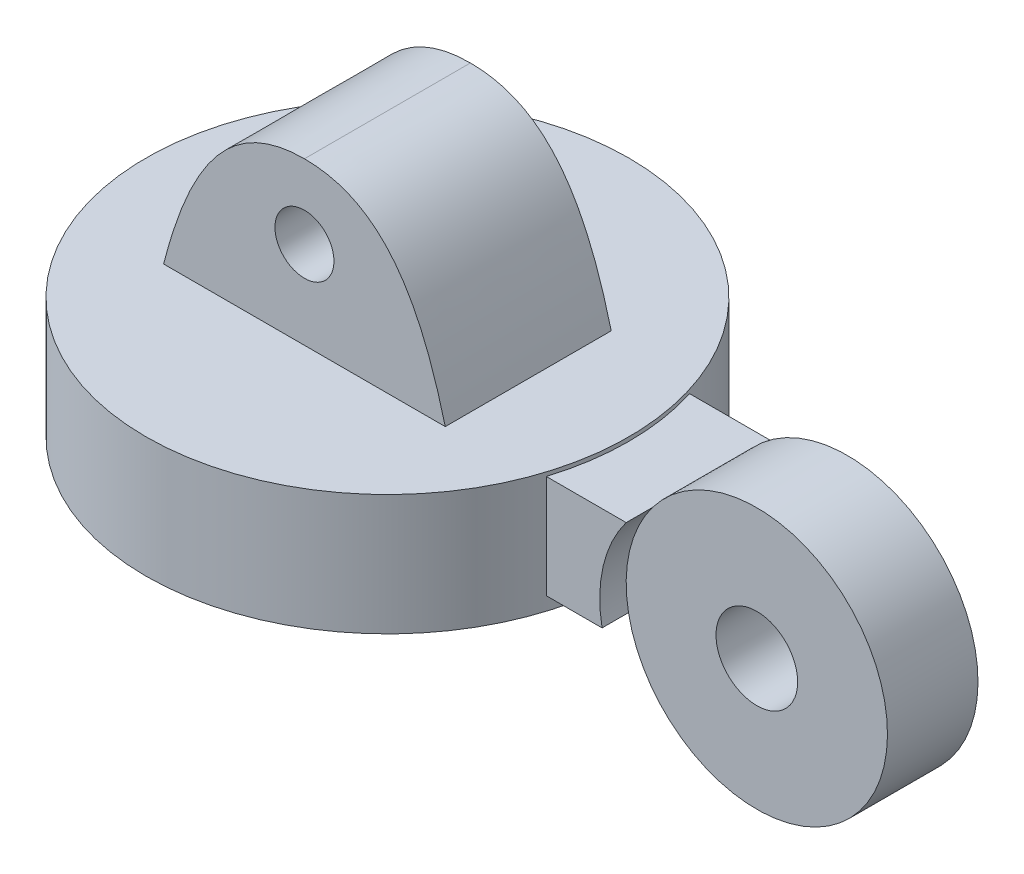
from build123d import *

# Parameters (mm, degrees)
SKETCH1_R           = 32.007465035
BOSS_EXTRUDE1_DEPTH = 16
SKETCH2_R           = 29.239508
SKETCH2_R_2         = 27.5
CUT_EXTRUDE1_DEPTH  = 3
SKETCH4_R           = 3.909700179
BOSS_EXTRUDE2_DEPTH = 11
BOSS_EXTRUDE3_DEPTH = 9.5
SKETCH5_3_R         = 5.411731441
BOSS_EXTRUDE4_DEPTH = 6


with BuildPart() as part:
    # Sketch1 → Boss-Extrude1 (new body)
    with BuildSketch(Plane(origin=(0, 0, 0), x_dir=(1, 0, 0), z_dir=(0, 1, 0))):
        Circle(SKETCH1_R)
    extrude(amount=BOSS_EXTRUDE1_DEPTH)

    # Sketch2 → Cut-Extrude1 (cut)
    with BuildSketch(Plane.XZ):
        Circle(SKETCH2_R)
        with Locations((-0.468052939, 0)):
            Circle(SKETCH2_R_2, mode=Mode.SUBTRACT)
    extrude(amount=-CUT_EXTRUDE1_DEPTH, mode=Mode.SUBTRACT)

    # Sketch4 → Boss-Extrude2 (add, symmetric)
    with BuildSketch(Plane.XY):
        with BuildLine():
            Line((18.666452957, 16), (-18.666452957, 16))
            add(Edge.make_bspline(
                [(-18.666452957, 16), (-15.111428576, 29.88911488), (-9.66036104, 37.412417949), (0, 37.412417949)],
                knots=[0, 0, 0, 0, 1, 1, 1, 1], degree=3))
            add(Edge.make_bspline(
                [(18.666452957, 16), (15.111428576, 29.88911488), (9.66036104, 37.412417949), (0, 37.412417949)],
                knots=[0, 0, 0, 0, 1, 1, 1, 1], degree=3))
        make_face()
        with Locations((0, 27.602784745)):
            Circle(SKETCH4_R, mode=Mode.SUBTRACT)
    extrude(amount=BOSS_EXTRUDE2_DEPTH, both=True)

    # Sketch5 → Boss-Extrude3 (add, symmetric)
    with BuildSketch(Plane.XY):
        with BuildLine():
            Line((25.328766218, 15.47490242), (25.328766218, 1.783805038))
            Line((25.328766218, 1.783805038), (37.952037716, 1.783805038))
            ThreePointArc((37.952037716, 1.783805038), (38.098309535, 8.968254235), (41.148102169, 15.47490242))
            Line((41.148102169, 15.47490242), (25.328766218, 15.47490242))
        make_face()
    extrude(amount=BOSS_EXTRUDE3_DEPTH, both=True)

    # Sketch5_3 → Boss-Extrude4 (add, symmetric)
    with BuildSketch(Plane.XY):
        with BuildLine():
            ThreePointArc((41.148102169, 15.47490242), (38.098309535, 8.968254235), (37.952037716, 1.783805038))
            ThreePointArc((37.952037716, 1.783805038), (56.594675341, -12.210746796), (72.282625116, 5.031168716))
            ThreePointArc((72.282625116, 5.031168716), (60.471563722, 21.450898409), (41.148102169, 15.47490242))
        make_face()
        with Locations((54.96374577, 5.031168716)):
            Circle(SKETCH5_3_R, mode=Mode.SUBTRACT)
    extrude(amount=BOSS_EXTRUDE4_DEPTH, both=True)


solid = part.part
